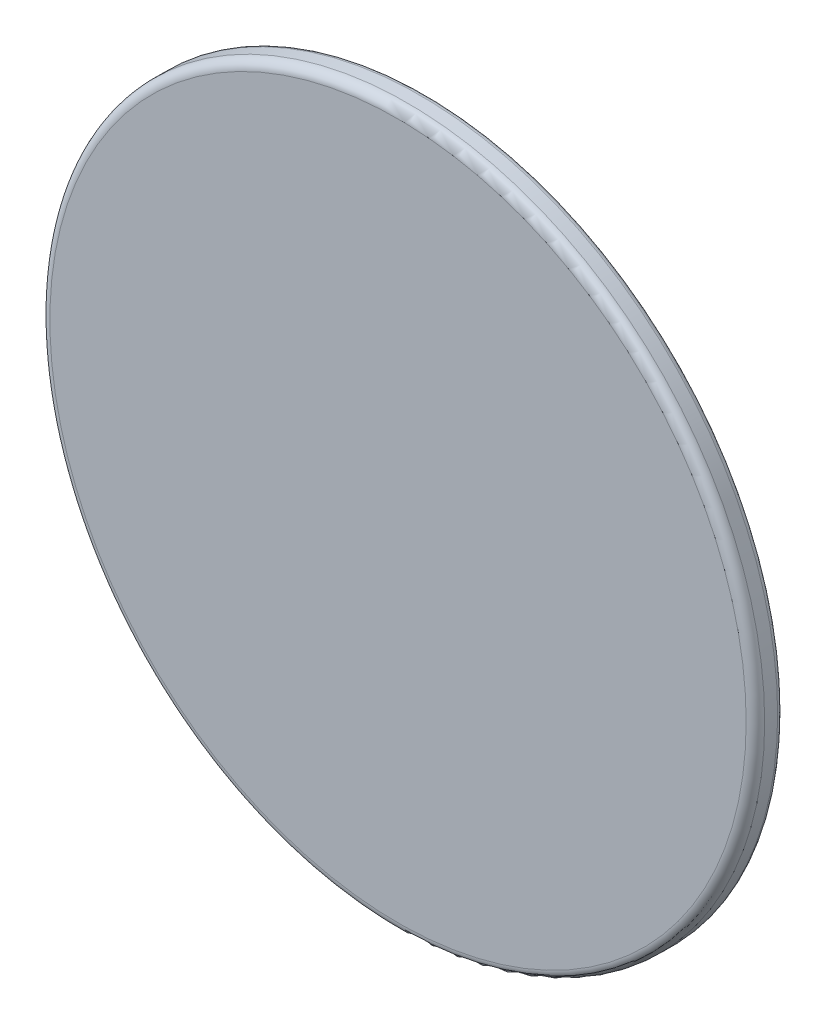
from build123d import *

# Parameters (mm, degrees)
ESQUISSE1_R             = 19.3
BOSS_EXTRU_1_DEPTH      = 1.5
ESQUISSE3_R             = 18
ENL_V_MAT_EXTRU_2_DEPTH = 1
CONG_1_R                = 0.5
CONG_2_R                = 0.3


with BuildPart() as part:
    # Esquisse1 → Boss.-Extru.1 (new body)
    with BuildSketch(Plane.XY):
        Circle(ESQUISSE1_R)
    extrude(amount=BOSS_EXTRU_1_DEPTH)

    # Esquisse3 → Enlèv. mat.-Extru.2 (cut)
    with BuildSketch(Plane(origin=(0, 0, 0), x_dir=(-1, 0, 0), z_dir=(0, 0, -1))):
        Circle(ESQUISSE3_R)
    extrude(amount=-ENL_V_MAT_EXTRU_2_DEPTH, mode=Mode.SUBTRACT)

    # Congé1
    cong_1_edges = [part.edges().sort_by_distance(p)[0] for p in [
        (-19.3, 0, 1.5),
    ]]
    fillet(cong_1_edges, radius=CONG_1_R)

    # Congé2
    cong_2_edges = [part.edges().sort_by_distance(p)[0] for p in [
        (-19.3, 0, 0),
    ]]
    fillet(cong_2_edges, radius=CONG_2_R)


solid = part.part
